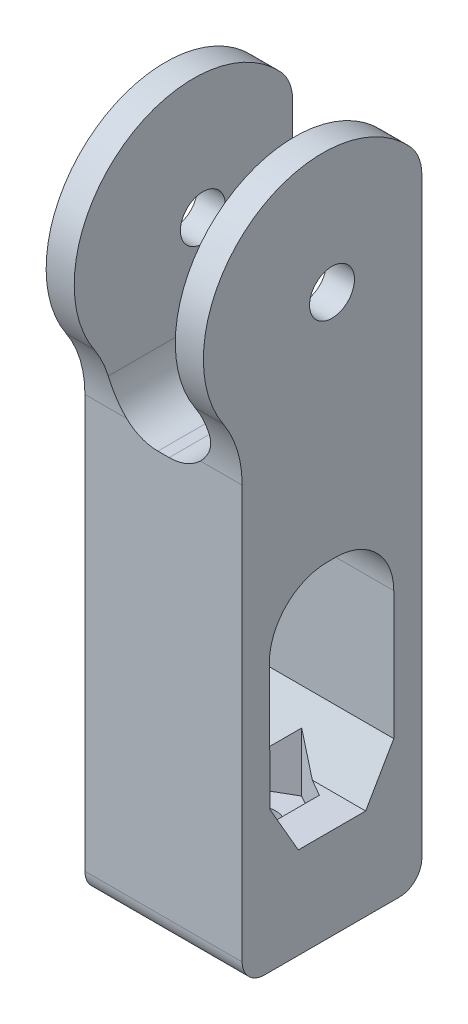
from build123d import *
from OCP.BRepFilletAPI import BRepFilletAPI_MakeChamfer

# Parameters (mm, degrees)
SKETCH9_R           = 2
BOSS_EXTRUDE3_DEPTH = 14
SKETCH10_R          = 2
CUT_EXTRUDE7_DEPTH  = 14
SKETCH11_W          = 9
SKETCH11_H          = 26.686138344
CUT_EXTRUDE8_DEPTH  = 28
FILLET1_R           = 2
CHAMFER1_SIZE       = 2.5
CHAMFER1_SIZE2      = 4.365846821
CHAMFER1_SIZE2_2    = 4.330127019
EXTRUDE1_DEPTH      = 3
EXTRUDE1_DEPTH_BACK = 3
FILLET2_R           = 4


with BuildPart() as part:
    # Sketch9 → Boss-Extrude3 (new body)
    with BuildSketch(Plane(origin=(0, 0, 0), x_dir=(0, 0, -1), z_dir=(1, 0, 0))):
        with BuildLine():
            Line((8, 5.053889445), (8, -49.642014822))
            Line((8, -49.642014822), (-8, -49.642014822))
            Line((-8, -49.642014822), (-8, -10.875806049))
            ThreePointArc((-8, -10.875806049), (-8.427714838, -7.982476346), (-9.674271354, -5.336650652))
            ThreePointArc((-9.674271354, -5.336650652), (-7.418447874, 8.870328147), (6.925281884, 7.78202542))
            ThreePointArc((6.925281884, 7.78202542), (7.721634556, 6.519985019), (8, 5.053889445))
        make_face()
        Circle(SKETCH9_R, mode=Mode.SUBTRACT)
        with BuildLine():
            Line((5.5, -41.5), (5.5, -25.762364524))
            ThreePointArc((5.5, -25.762364524), (3.987567872, -22.111030369), (0.336233717, -20.598598241))
            Line((0.336233717, -20.598598241), (-0.410415455, -20.598598241))
            ThreePointArc((-0.410415455, -20.598598241), (-4.070351606, -22.119652678), (-5.574124284, -25.786723302))
            Line((-5.574124284, -25.786723302), (-5.5, -41.5))
            Line((-5.5, -41.5), (5.5, -41.5))
        make_face(mode=Mode.SUBTRACT)
    extrude(amount=BOSS_EXTRUDE3_DEPTH)

    # Sketch10 → Cut-Extrude7 (cut)
    with BuildSketch(Plane.XZ.offset(49.642014822)):
        with Locations(Location((7, 0, 0), (0, 0, 270))):
            Circle(SKETCH10_R)
    extrude(amount=-CUT_EXTRUDE7_DEPTH, mode=Mode.SUBTRACT)

    # Sketch11 → Cut-Extrude8 (cut)
    with BuildSketch(Plane(origin=(0, 16, 0), x_dir=(1, 0, 0), z_dir=(0, 1, 0))):
        with Locations((7, -2.737831409)):
            Rectangle(SKETCH11_W, SKETCH11_H)
    extrude(amount=-CUT_EXTRUDE8_DEPTH, mode=Mode.SUBTRACT)

    # Fillet1
    fillet1_edges = [part.edges().sort_by_distance(p)[0] for p in [
        (7, -49.642014822, 8),
        (7, -49.642014822, -8),
    ]]
    fillet(fillet1_edges, radius=FILLET1_R)

    # Chamfer1: one chamfer whose edges measure the first distance from different faces: ONE call of the kernel's chamfer builder (chamfer() names one face for all edges)
    chamfer1_edges_1 = [part.edges().sort_by_distance(p)[0] for p in [
        (7, -41.5, 5.5),
    ]]
    chamfer1_side_1 = [part.faces().sort_by_distance(p)[0] for p in [
        (7, -41.5, 5.321955062),
    ]]
    chamfer1_edges_2 = [part.edges().sort_by_distance(p)[0] for p in [
        (7, -41.5, -5.5),
    ]]
    chamfer1_side_2 = [part.faces().sort_by_distance(p)[0] for p in [
        (7, -41.5, 5.321955062),
    ]]
    chamfer1 = BRepFilletAPI_MakeChamfer(part.part.solid().wrapped)
    for e in chamfer1_edges_1:
        chamfer1.Add(CHAMFER1_SIZE, CHAMFER1_SIZE2, e.wrapped, chamfer1_side_1[0].wrapped)  # the first distance lies on this face
    for e in chamfer1_edges_2:
        chamfer1.Add(CHAMFER1_SIZE, CHAMFER1_SIZE2_2, e.wrapped, chamfer1_side_2[0].wrapped)  # the first distance lies on this face
    add(Compound.cast(chamfer1.Shape()), mode=Mode.REPLACE)

    # Sketch12 → Extrude1 (cut, two sides)
    with BuildSketch(Plane(origin=(0, -41.5, 0), x_dir=(1, 0, 0), z_dir=(0, 1, 0))) as extrude1_sk:
        Polygon((7, 4.3), (3.276090764, 2.15), (3.276090764, -2.15), (7, -4.3), (10.723909236, -2.15), (10.723909236, 2.15), align=None)
    extrude(amount=EXTRUDE1_DEPTH, mode=Mode.SUBTRACT)
    extrude(extrude1_sk.sketch, amount=-EXTRUDE1_DEPTH_BACK, mode=Mode.SUBTRACT)

    # Fillet2
    fillet2_edges = [part.edges().sort_by_distance(p)[0] for p in [
        (2.5, -12, 0),
        (11.5, -12, 0),
    ]]
    fillet(fillet2_edges, radius=FILLET2_R)


solid = part.part
